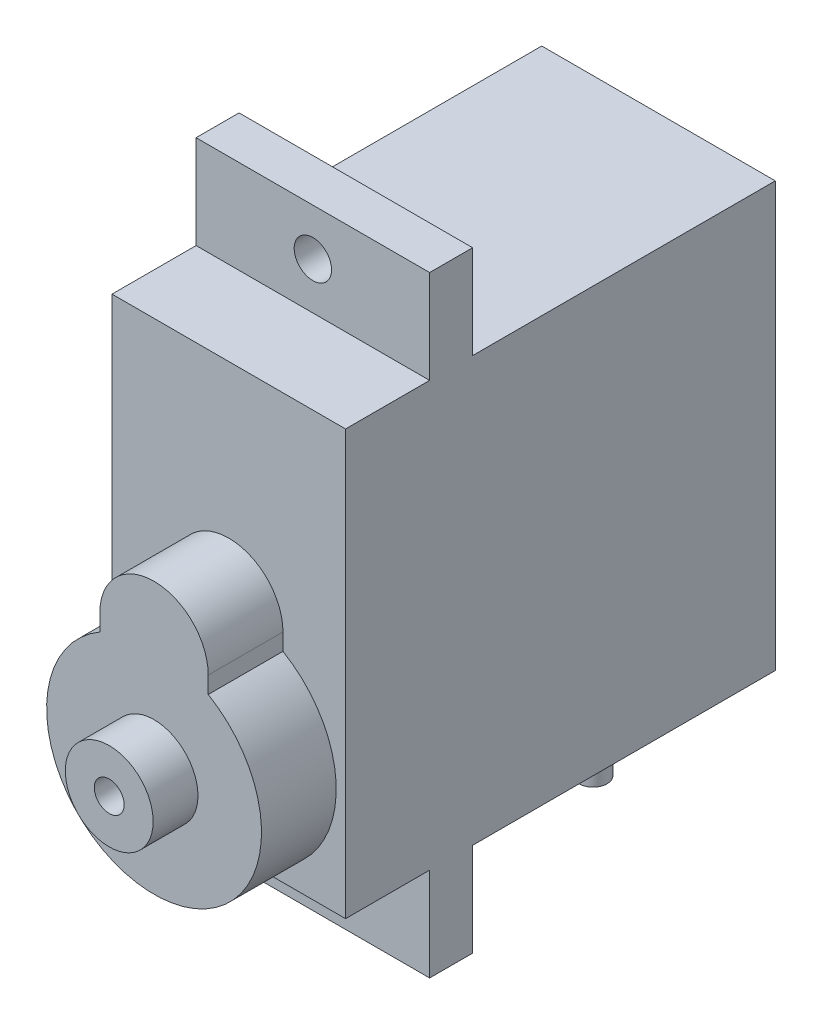
from build123d import *

# Parameters (mm, degrees)
CROQUIS1_W              = 12.5
CROQUIS1_H              = 22.7
SALIENTE_EXTRUIR1_DEPTH = 23
SALIENTE_EXTRUIR2_DEPTH = 4
CROQUIS3_W              = 2.3
CROQUIS3_H              = 5
SALIENTE_EXTRUIR3_DEPTH = 6.25
CORTAR_EXTRUIR1_REACH   = 20.5
CROQUIS4_R              = 1
SALIENTE_EXTRUIR4_START = -4
CROQUIS5_W              = 4
CROQUIS5_H              = 5
SALIENTE_EXTRUIR4_DEPTH = 1.5
CROQUIS6_R              = 2.35
CROQUIS6_R_2            = 0.8
SALIENTE_EXTRUIR5_DEPTH = 2.4
SKETCH1_W               = 4.514706964
SKETCH1_H               = 2.103718672
CUT_EXTRUDE2_DEPTH      = 5


with BuildPart() as part:
    # Croquis1 → Saliente-Extruir1 (new body)
    with BuildSketch(Plane.XY):
        Rectangle(CROQUIS1_W, CROQUIS1_H)
    extrude(amount=SALIENTE_EXTRUIR1_DEPTH)

    # Croquis2 → Saliente-Extruir2 (add)
    with BuildSketch(Plane.XY.offset(23)):
        with BuildLine():
            Line((2.9, 0.265128397), (2.9, -0.634871603))
            ThreePointArc((2.9, -0.634871603), (0, -11.35), (-2.9, -0.634871603))
            Line((-2.9, -0.634871603), (-2.9, 0.265128397))
            ThreePointArc((-2.9, 0.265128397), (0, 3.165128397), (2.9, 0.265128397))
        make_face()
    extrude(amount=SALIENTE_EXTRUIR2_DEPTH)

    # Croquis3 → Saliente-Extruir3 (add, symmetric)
    with BuildSketch(Plane(origin=(0, 0, 0), x_dir=(0, 0, -1), z_dir=(1, 0, 0))):
        with Locations((-17.35, 13.85)):
            Rectangle(CROQUIS3_W, CROQUIS3_H)
        with Locations((-17.35, -13.85)):
            Rectangle(CROQUIS3_W, CROQUIS3_H)
    extrude(amount=SALIENTE_EXTRUIR3_DEPTH, both=True)

    # Croquis4 → Cortar-Extruir1 (cut, up to next)
    with BuildSketch(Plane.XY.offset(18.5), mode=Mode.PRIVATE) as cortar_extruir1_sk1:
        with Locations((0, 13.85)):
            Circle(CROQUIS4_R)
    cortar_extruir1_tool1 = extrude(cortar_extruir1_sk1.sketch, amount=-CORTAR_EXTRUIR1_REACH, mode=Mode.PRIVATE) & part.part
    add(cortar_extruir1_tool1.solids().sort_by_distance((0, 13.85, 18.5))[0], mode=Mode.SUBTRACT)
    # Croquis4 → Cortar-Extruir1 (cut, up to next)
    with BuildSketch(Plane.XY.offset(18.5), mode=Mode.PRIVATE) as cortar_extruir1_sk2:
        with Locations((0, -13.85)):
            Circle(CROQUIS4_R)
    cortar_extruir1_tool2 = extrude(cortar_extruir1_sk2.sketch, amount=-CORTAR_EXTRUIR1_REACH, mode=Mode.PRIVATE) & part.part
    add(cortar_extruir1_tool2.solids().sort_by_distance((0, -13.85, 18.5))[0], mode=Mode.SUBTRACT)

    # Croquis5 → Saliente-Extruir4 (add)
    with BuildSketch(Plane(origin=(0, 0, 0), x_dir=(-1, 0, 0), z_dir=(0, 0, -1)).offset(SALIENTE_EXTRUIR4_START)):
        with Locations((0, -13.85)):
            Rectangle(CROQUIS5_W, CROQUIS5_H)
    extrude(amount=-SALIENTE_EXTRUIR4_DEPTH)

    # Croquis6 → Saliente-Extruir5 (add)
    with BuildSketch(Plane.XY.offset(27)):
        with Locations((0, -5.6)):
            Circle(CROQUIS6_R)
        with Locations((0, -5.6)):
            Circle(CROQUIS6_R_2, mode=Mode.SUBTRACT)
    extrude(amount=SALIENTE_EXTRUIR5_DEPTH)

    # Sketch1 → Cut-Extrude2 (cut)
    with BuildSketch(Plane.XZ.offset(16.35)):
        with Locations((0, 4.75)):
            Rectangle(SKETCH1_W, SKETCH1_H)
        with BuildLine():
            ThreePointArc((-0.625, 4.335421901), (-2, 4.75), (-0.625, 5.164578099))
            ThreePointArc((-0.625, 5.164578099), (0, 5.5), (0.625, 5.164578099))
            ThreePointArc((0.625, 5.164578099), (2, 4.75), (0.625, 4.335421901))
            ThreePointArc((0.625, 4.335421901), (0, 4), (-0.625, 4.335421901))
        make_face(mode=Mode.SUBTRACT)
    extrude(amount=-CUT_EXTRUDE2_DEPTH, mode=Mode.SUBTRACT)


solid = part.part
